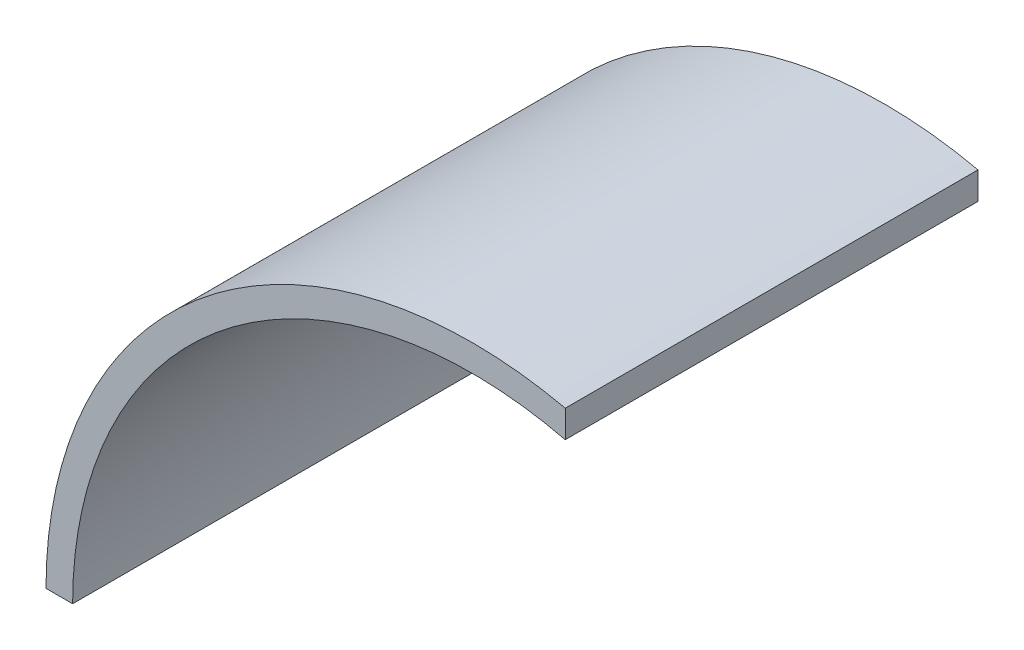
from build123d import *

# Parameters (mm, degrees)
INNER_RING_LEFT_SIDE_DEPTH = 155


with BuildPart() as part:
    # Sketch1 → Inner Ring - Left Side (new body)
    with BuildSketch(Plane.XY):
        with BuildLine():
            Line((35, 156.12494996), (35, 145.859521458))
            ThreePointArc((35, 145.859521458), (-92.870878105, 117.792189894), (-150, 0))
            Line((-150, 0), (-160, 0))
            ThreePointArc((-160, 0), (-100, 124.899959968), (35, 156.12494996))
        make_face()
    extrude(amount=INNER_RING_LEFT_SIDE_DEPTH)


solid = part.part
